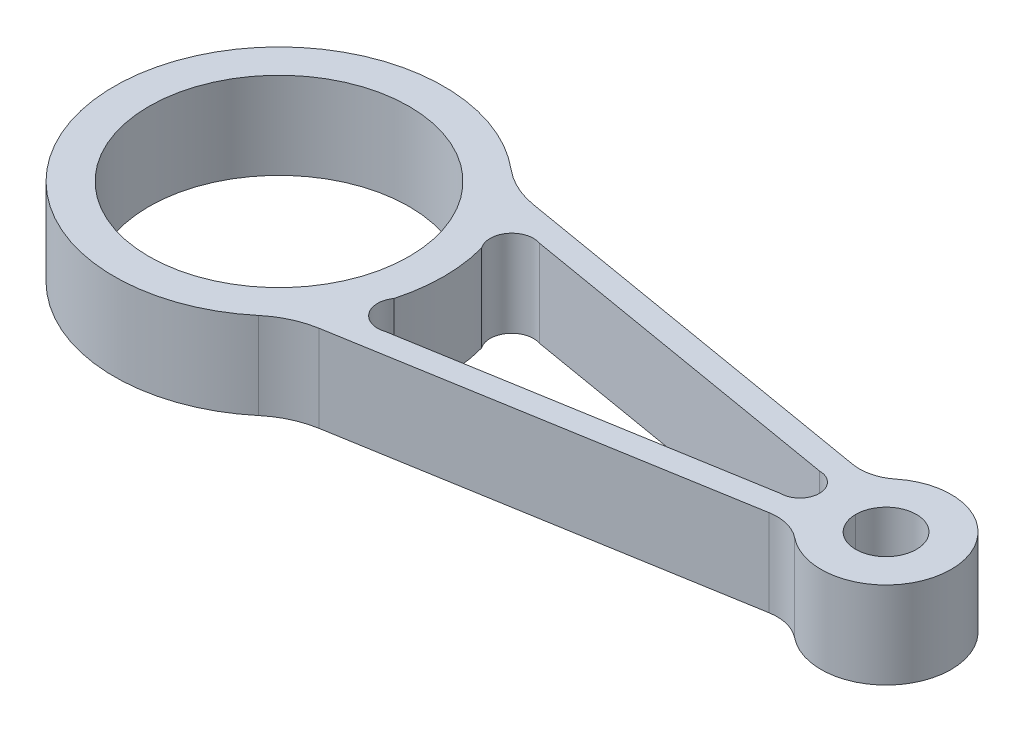
from build123d import *

# Parameters (mm, degrees)
SKETCH1_R           = 30
SKETCH1_R_2         = 7
BOSS_EXTRUDE1_DEPTH = 10
FILLET1_R           = 10
FILLET2_R           = 20
CUT_EXTRUDE1_DEPTH  = 21


with BuildPart() as part:
    # Sketch1 → Boss-Extrude1 (new body, symmetric)
    with BuildSketch(Plane(origin=(0, 0, 0), x_dir=(1, 0, 0), z_dir=(0, 1, 0))):
        with BuildLine():
            Line((9.080898408, 13.654134499), (-90.777819418, 30.604008061))
            ThreePointArc((-90.777819418, 30.604008061), (-156.75035362, 4.883640056), (-90.777819418, -20.836727949))
            Line((-90.777819418, -20.836727949), (9.080898408, -3.886854388))
            ThreePointArc((9.080898408, -3.886854388), (36.24964638, 4.883640056), (9.080898408, 13.654134499))
        make_face()
        with Locations((-118.75035362, 4.883640056)):
            Circle(SKETCH1_R, mode=Mode.SUBTRACT)
        with Locations((21.24964638, 4.883640056)):
            Circle(SKETCH1_R_2, mode=Mode.SUBTRACT)
    extrude(amount=BOSS_EXTRUDE1_DEPTH, both=True)

    # Fillet1
    fillet1_edges = [part.edges().sort_by_distance(p)[0] for p in [
        (9.080898408, 0, -13.654134499),
        (9.080898408, 0, 3.886854388),
    ]]
    fillet(fillet1_edges, radius=FILLET1_R)

    # Fillet2
    fillet2_edges = [part.edges().sort_by_distance(p)[0] for p in [
        (-90.777819418, 0, 20.836727949),
        (-90.777819418, 0, -30.604008061),
    ]]
    fillet(fillet2_edges, radius=FILLET2_R)

    # Sketch2 → Cut-Extrude1 (cut, through all)
    with BuildSketch(Plane(origin=(0, 10, 0), x_dir=(1, 0, 0), z_dir=(0, 1, 0))):
        with BuildLine():
            Line((-76.385663344, 22.582436294), (1.373906039, 9.383640056))
            ThreePointArc((1.373906039, 9.383640056), (5.873906039, 4.883640056), (1.373906039, 0.383640056))
            Line((1.373906039, 0.383640056), (-76.385663344, -12.815156183))
            ThreePointArc((-76.385663344, -12.815156183), (-82.031183012, -11.100966392), (-82.113079878, -5.201506089))
            ThreePointArc((-82.113079878, -5.201506089), (-80.75035362, 4.883640056), (-82.113079878, 14.968786201))
            ThreePointArc((-82.113079878, 14.968786201), (-82.031183012, 20.868246504), (-76.385663344, 22.582436294))
        make_face()
    extrude(amount=-CUT_EXTRUDE1_DEPTH, mode=Mode.SUBTRACT)


solid = part.part
